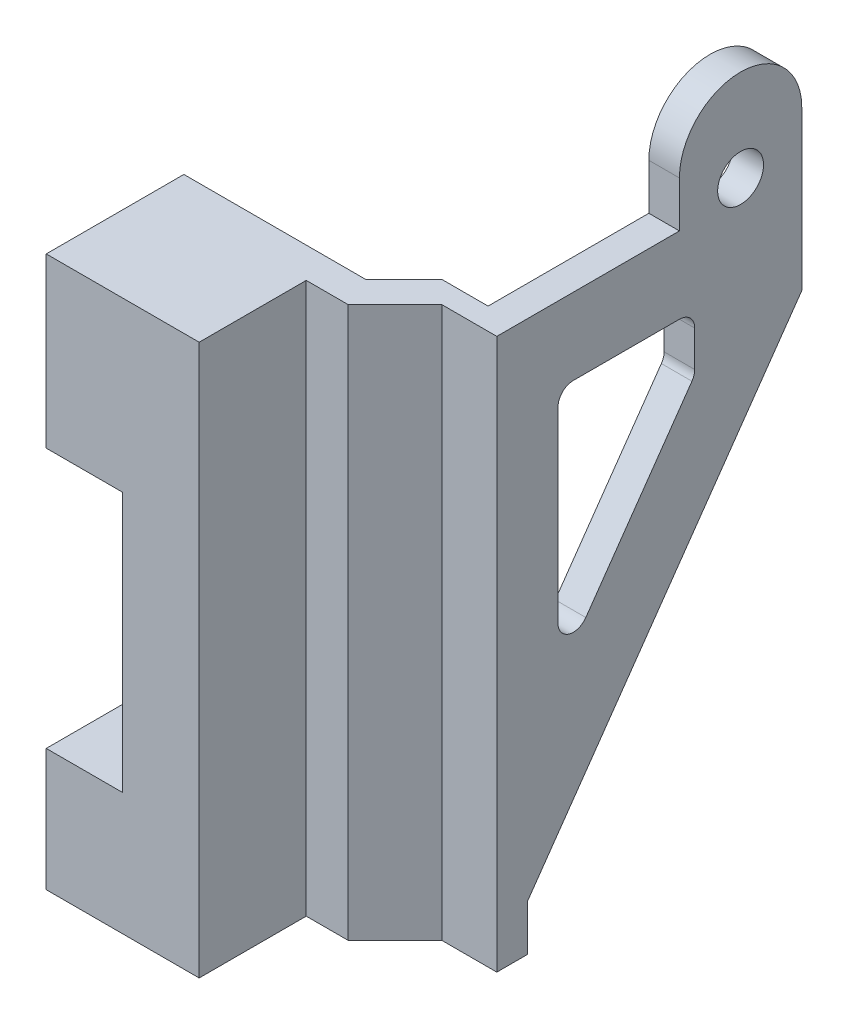
from build123d import *

# Parameters (mm, degrees)
BOSS_EXTRUDE1_DEPTH = 36
CUT_EXTRUDE1_REACH  = 21.399
CUT_EXTRUDE2_REACH  = 21.399
BOSS_EXTRUDE2_DEPTH = 2
CUT_EXTRUDE3_REACH  = 21.399
SKETCH5_R           = 1.5
CUT_EXTRUDE4_REACH  = 11
SKETCH6_W           = 5
SKETCH6_H           = 17


with BuildPart() as part:
    # Sketch1 → Boss-Extrude1 (new body)
    with BuildSketch(Plane(origin=(0, 0, 0), x_dir=(1, 0, 0), z_dir=(0, 1, 0))):
        Polygon((0, 0), (11.909668113, 0), (14.399319728, 2.489651615), (17.399319728, 2.489651615), (17.399319728, 21), (19.399319728, 21), (19.399319728, 1.06122449), (15.799319728, 1.06122449), (12.738095238, -2), (10, -2), (10, -9), (0, -9), align=None)
    extrude(amount=BOSS_EXTRUDE1_DEPTH)

    # Sketch2 → Cut-Extrude1 (cut, up to next)
    with BuildSketch(Plane(origin=(19.399319728, 0, 0), x_dir=(0, 0, -1), z_dir=(1, 0, 0)), mode=Mode.PRIVATE) as cut_extrude1_sk1:
        Polygon((3.06122449, 0), (3.06122449, 3), (21, 28.619226488), (21, 0), align=None)
    cut_extrude1_tool1 = extrude(cut_extrude1_sk1.sketch, amount=-CUT_EXTRUDE1_REACH, mode=Mode.PRIVATE) & part.part
    add(cut_extrude1_tool1.solids().sort_by_distance((19.39932, 9.634621, -14.453071))[0], mode=Mode.SUBTRACT)

    # Sketch3 → Cut-Extrude2 (cut, up to next)
    with BuildSketch(Plane(origin=(19.399319728, 0, 0), x_dir=(0, 0, -1), z_dir=(1, 0, 0)), mode=Mode.PRIVATE) as cut_extrude2_sk1:
        with BuildLine():
            Line((5.06122449, 17.745124794), (5.06122449, 30))
            ThreePointArc((5.06122449, 30), (5.354117709, 30.707106781), (6.06122449, 31))
            Line((6.06122449, 31), (13, 31))
            ThreePointArc((13, 31), (13.707106781, 30.707106781), (14, 30))
            Line((14, 30), (14, 27.654723208))
            ThreePointArc((14, 27.654723208), (13.953716951, 27.354017409), (13.819152044, 27.081146772))
            Line((13.819152044, 27.081146772), (6.880376534, 17.171548358))
            ThreePointArc((6.880376534, 17.171548358), (5.76051869, 16.791407843), (5.06122449, 17.745124794))
        make_face()
    cut_extrude2_tool1 = extrude(cut_extrude2_sk1.sketch, amount=-CUT_EXTRUDE2_REACH, mode=Mode.PRIVATE) & part.part
    add(cut_extrude2_tool1.solids().sort_by_distance((19.39932, 25.474687, -8.644546))[0], mode=Mode.SUBTRACT)

    # Sketch4 → Boss-Extrude2 (add)
    with BuildSketch(Plane(origin=(19.399319728, 0, 0), x_dir=(0, 0, -1), z_dir=(1, 0, 0))):
        with BuildLine():
            Line((21, 36), (21, 39))
            ThreePointArc((21, 39), (17, 43), (13, 39))
            Line((13, 39), (13, 36))
            Line((13, 36), (21, 36))
        make_face()
    extrude(amount=-BOSS_EXTRUDE2_DEPTH)

    # Sketch5 → Cut-Extrude3 (cut, up to next)
    with BuildSketch(Plane(origin=(19.399319728, 0, 0), x_dir=(0, 0, -1), z_dir=(1, 0, 0)), mode=Mode.PRIVATE) as cut_extrude3_sk1:
        with Locations((17, 37)):
            Circle(SKETCH5_R)
    cut_extrude3_tool1 = extrude(cut_extrude3_sk1.sketch, amount=-CUT_EXTRUDE3_REACH, mode=Mode.PRIVATE) & part.part
    add(cut_extrude3_tool1.solids().sort_by_distance((19.39932, 37, -17))[0], mode=Mode.SUBTRACT)

    # Sketch6 → Cut-Extrude4 (cut, up to next)
    with BuildSketch(Plane(origin=(0, 0, 0), x_dir=(-1, 0, 0), z_dir=(0, 0, -1)), mode=Mode.PRIVATE) as cut_extrude4_sk1:
        with Locations((-2.5, 16.5)):
            Rectangle(SKETCH6_W, SKETCH6_H)
    cut_extrude4_tool1 = extrude(cut_extrude4_sk1.sketch, amount=-CUT_EXTRUDE4_REACH, mode=Mode.PRIVATE) & part.part
    add(cut_extrude4_tool1.solids().sort_by_distance((2.5, 16.5, 0))[0], mode=Mode.SUBTRACT)


solid = part.part
